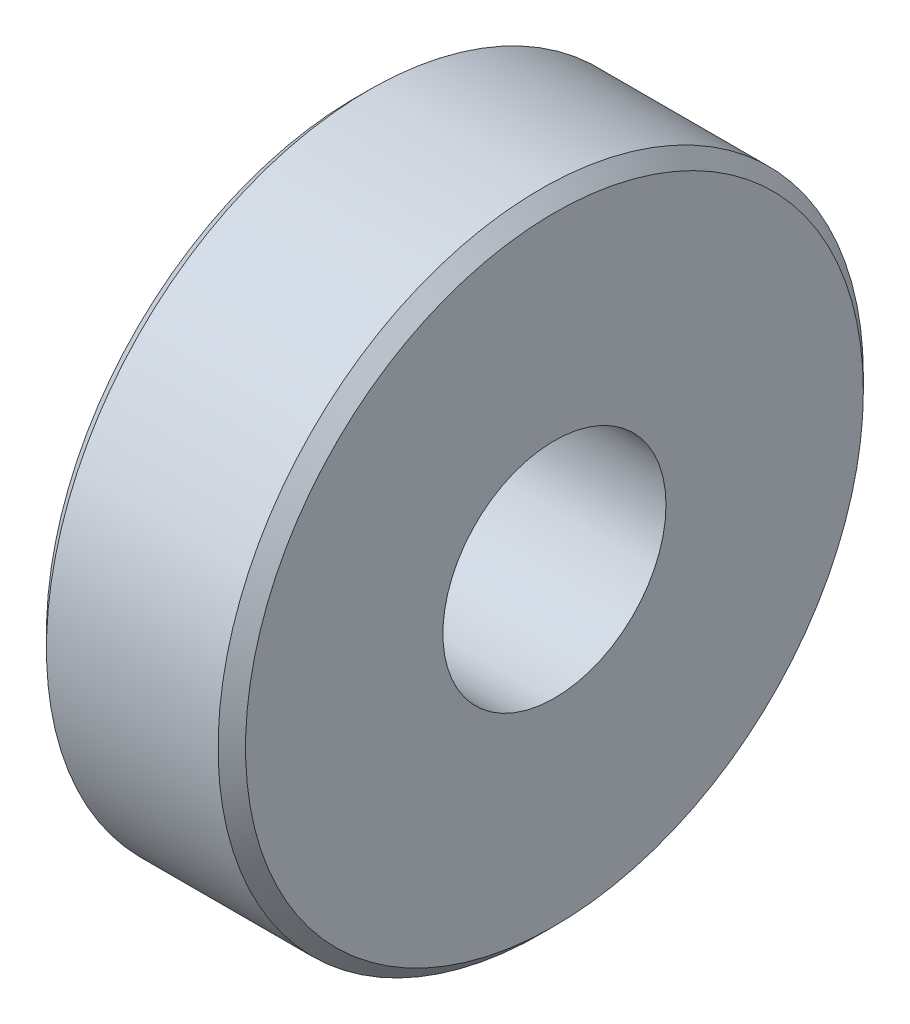
from build123d import *


with BuildPart() as part:
    # Sketch1 → Revolve1 (revolve)
    with BuildSketch(Plane.XY):
        Polygon((1.45, 1.625), (1.45, 4.5), (1.25, 4.7), (-1.25, 4.7), (-1.45, 4.5), (-1.45, 1.625), align=None)
    revolve(axis=Axis((4.137307633, 0, 0), (-1, 0, 0)))


solid = part.part
